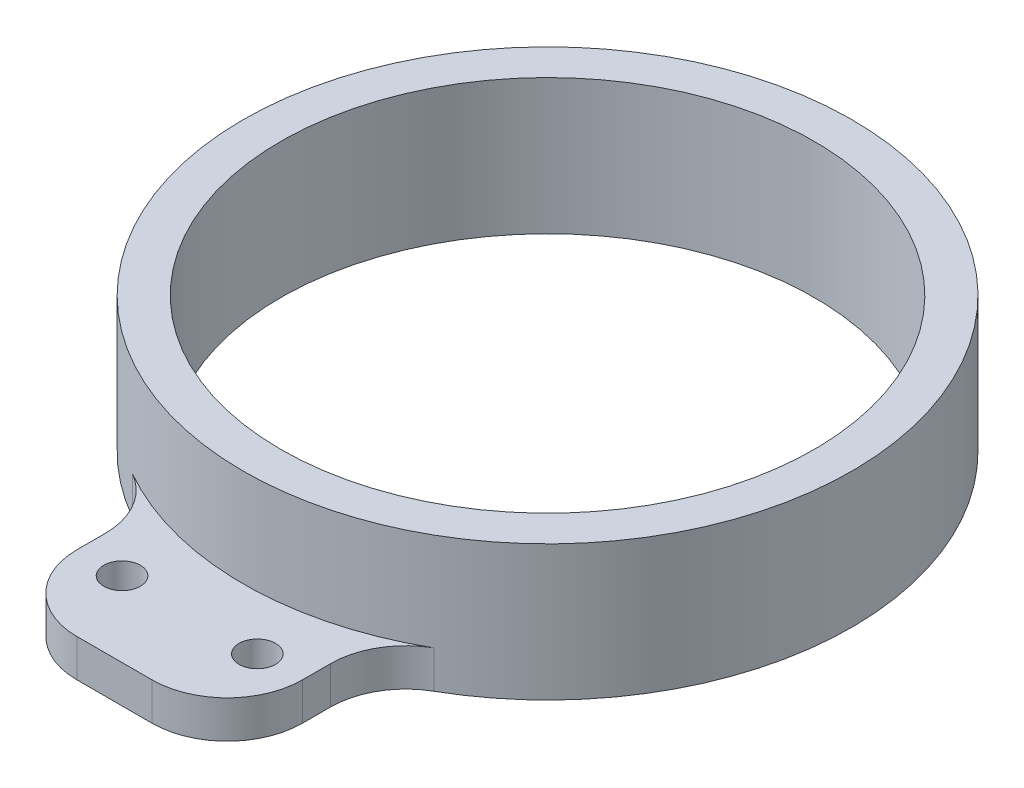
from build123d import *

# Parameters (mm, degrees)
CROQUIS1_R              = 40.5
CROQUIS1_R_2            = 35.5
SALIENTE_EXTRUIR1_DEPTH = 9
CROQUIS2_R              = 2.429274189
SALIENTE_EXTRUIR2_DEPTH = 5
REDONDEO1_R             = 10


with BuildPart() as part:
    # Croquis1 → Saliente-Extruir1 (new body, symmetric)
    with BuildSketch(Plane(origin=(0, 0, 0), x_dir=(1, 0, 0), z_dir=(0, 1, 0))):
        Circle(CROQUIS1_R)
        Circle(CROQUIS1_R_2, mode=Mode.SUBTRACT)
    extrude(amount=SALIENTE_EXTRUIR1_DEPTH, both=True)

    # Croquis2 → Saliente-Extruir2 (add)
    with BuildSketch(Plane.XZ.offset(9)):
        with BuildLine():
            Line((-15, 37.619808612), (-15, 57.619808612))
            Line((-15, 57.619808612), (15, 57.619808612))
            Line((15, 57.619808612), (15, 37.619808612))
            ThreePointArc((15, 37.619808612), (0, 40.5), (-15, 37.619808612))
        make_face()
        with Locations((-9, 47.619808612)):
            Circle(CROQUIS2_R, mode=Mode.SUBTRACT)
        with Locations((9, 47.619808612)):
            Circle(CROQUIS2_R, mode=Mode.SUBTRACT)
    extrude(amount=-SALIENTE_EXTRUIR2_DEPTH)

    # Redondeo1
    redondeo1_edges = [part.edges().sort_by_distance(p)[0] for p in [
        (15, -6.5, 37.619808612),
        (-15, -6.5, 37.619808612),
        (-15, -6.5, 57.619808612),
        (15, -6.5, 57.619808612),
    ]]
    fillet(redondeo1_edges, radius=REDONDEO1_R)


solid = part.part
